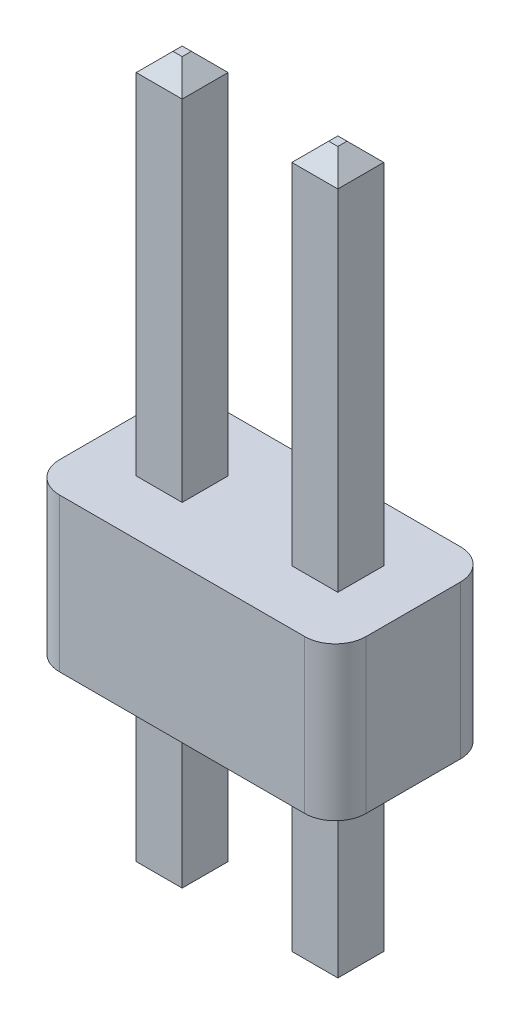
from build123d import *

# Parameters (mm, degrees)
BOSS_EXTRUDE1_DEPTH      = 2.5
SKETCH2_W                = 0.75
SKETCH2_H                = 0.75
BOSS_EXTRUDE2_DEPTH      = 8.5
BOSS_EXTRUDE2_DEPTH_BACK = 3.25
CHAMFER1_SIZE            = 0.3


with BuildPart() as part:
    # Sketch1 → Boss-Extrude1 (new body)
    with BuildSketch(Plane(origin=(0, 0, 0), x_dir=(-1, 0, 0), z_dir=(0, 1, 0))):
        with BuildLine():
            Line((-2, 1.27), (2, 1.27))
            ThreePointArc((2, 1.27), (2.353553391, 1.123553391), (2.5, 0.77))
            Line((2.5, 0.77), (2.5, -0.77))
            ThreePointArc((2.5, -0.77), (2.353553391, -1.123553391), (2, -1.27))
            Line((2, -1.27), (-2, -1.27))
            ThreePointArc((-2, -1.27), (-2.353553391, -1.123553391), (-2.5, -0.77))
            Line((-2.5, -0.77), (-2.5, 0.77))
            ThreePointArc((-2.5, 0.77), (-2.353553391, 1.123553391), (-2, 1.27))
        make_face()
    extrude(amount=BOSS_EXTRUDE1_DEPTH)

    # Sketch2 → Boss-Extrude2 (add, two sides)
    with BuildSketch(Plane(origin=(0, 0, 0), x_dir=(-1, 0, 0), z_dir=(0, 1, 0))) as boss_extrude2_sk:
        with Locations((1.27, 0)):
            Rectangle(SKETCH2_W, SKETCH2_H)
        with Locations((-1.27, 0)):
            Rectangle(SKETCH2_W, SKETCH2_H)
    extrude(amount=BOSS_EXTRUDE2_DEPTH)
    extrude(boss_extrude2_sk.sketch, amount=-BOSS_EXTRUDE2_DEPTH_BACK)

    # Chamfer1
    chamfer1_edges = [part.edges().sort_by_distance(p)[0] for p in [
        (-0.895, -3.25, 0),
        (-1.27, -3.25, 0.375),
        (-1.645, -3.25, 0),
        (-1.27, -3.25, -0.375),
        (-0.895, 8.5, 0),
        (-1.27, 8.5, -0.375),
        (-1.645, 8.5, 0),
        (-1.27, 8.5, 0.375),
        (0.895, -3.25, 0),
        (1.27, -3.25, -0.375),
        (1.645, -3.25, 0),
        (1.27, -3.25, 0.375),
        (0.895, 8.5, 0),
        (1.27, 8.5, 0.375),
        (1.645, 8.5, 0),
        (1.27, 8.5, -0.375),
    ]]
    chamfer(chamfer1_edges, length=CHAMFER1_SIZE)


solid = part.part
